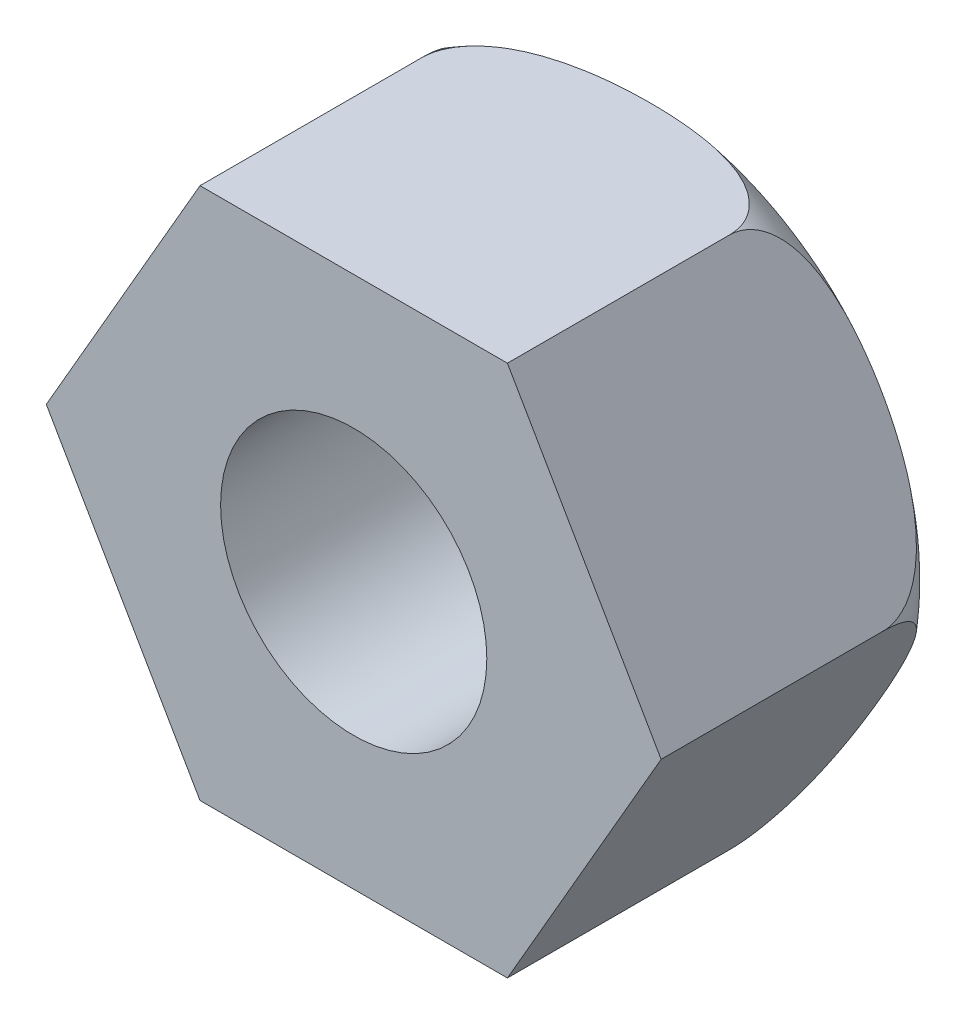
from build123d import *

# Parameters (mm, degrees)
BOSS_EXTRUDE1_DEPTH = 35
SKETCH2_R           = 15
CUT_EXTRUDE1_DEPTH  = 35


with BuildPart() as part:
    # Sketch1 → Boss-Extrude1 (new body)
    with BuildSketch(Plane.XY):
        Polygon((-34.641016151, 0), (-17.320508076, -30), (17.320508076, -30), (34.641016151, 0), (17.320508076, 30), (-17.320508076, 30), align=None)
    extrude(amount=BOSS_EXTRUDE1_DEPTH)

    # Sketch2 → Cut-Extrude1 (cut)
    with BuildSketch(Plane.XY.offset(35)):
        Circle(SKETCH2_R)
    extrude(amount=-CUT_EXTRUDE1_DEPTH, mode=Mode.SUBTRACT)

    # Sketch3 → Cut-Revolve1 (revolve, cut)
    with BuildSketch(Plane(origin=(0, 0, 0), x_dir=(1, 0, 0), z_dir=(0, 1, 0))):
        with BuildLine():
            Line((24.641016151, 0), (34.641016151, 0))
            Line((34.641016151, 0), (34.641016151, -10))
            ThreePointArc((34.641016151, -10), (31.712083963, -2.928932188), (24.641016151, 0))
        make_face()
    revolve(axis=Axis((0, 0, 0), (0, 0, 1)), mode=Mode.SUBTRACT)


solid = part.part
